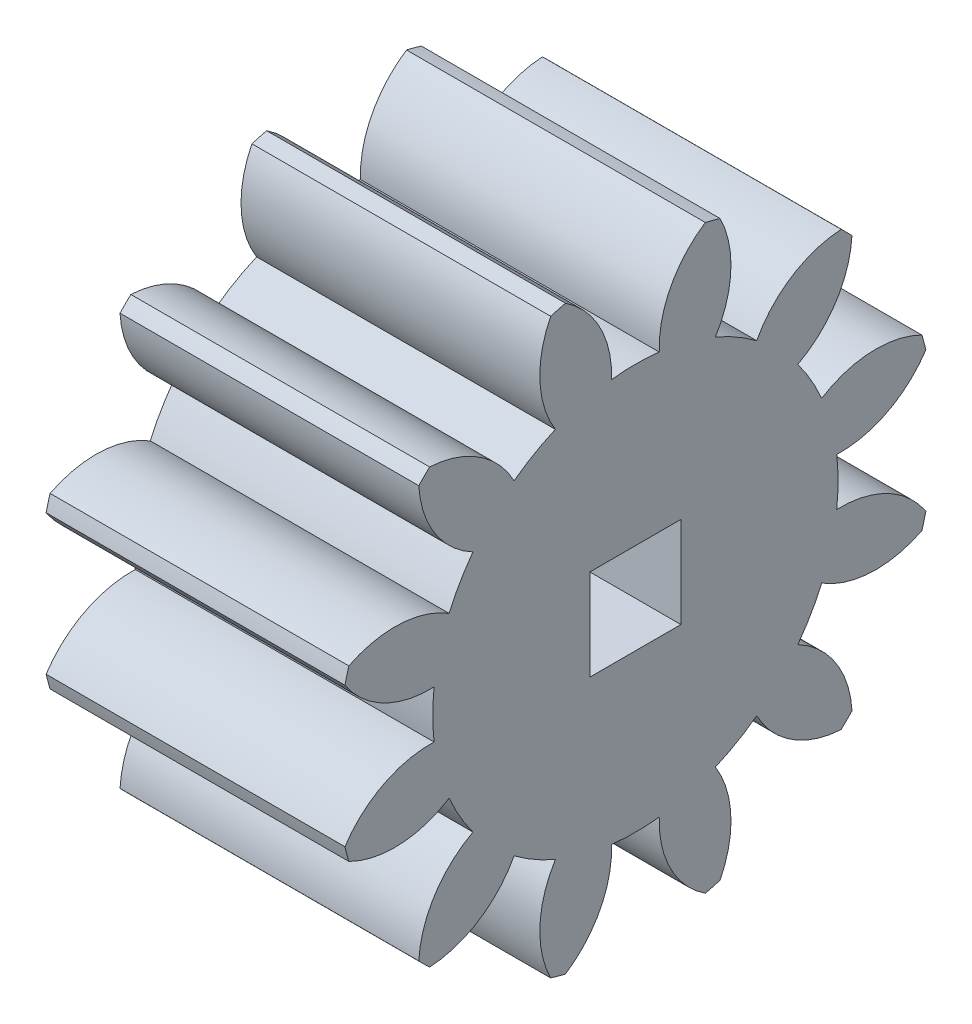
from build123d import *

# Parameters (mm, degrees)
BASPROSKE_W        = 10.5
BASPROSKE_H        = 10.5
TOOTHCUT_DEPTH     = 19.186533479
TEETHCUTS_COUNT    = 12
TEETHCUTS_ANGLE    = 330
BORSKE_R           = 0.5
BORE_DEPTH         = 50.0000508
SKETCH1_W          = 3.2
SKETCH1_H          = 3.2
CUT_EXTRUDE1_DEPTH = 30


with BuildPart() as part:
    # BasProSke → Base-Revolve (revolve)
    with BuildSketch(Plane(origin=(0, 0, 0), x_dir=(1, 0, 0), z_dir=(0, 1, 0)), mode=Mode.PRIVATE) as base_revolve_sk:
        with Locations((5.25, 5.25)):
            Rectangle(BASPROSKE_W, BASPROSKE_H)
    revolve(base_revolve_sk.sketch.rotate(Axis((-10, 0, 0), (1, 0, 0)), 180), axis=Axis((-10, 0, 0), (1, 0, 0)))

    # TooCutSke → ToothCut (cut, through all)
    with BuildSketch(Plane(origin=(0, 0, 0), x_dir=(0, 0, -1), z_dir=(1, 0, 0))):
        with BuildLine():
            ThreePointArc((0.837751456, 7.074570552), (0, 7.124), (-0.837751456, 7.074570552))
            ThreePointArc((-0.837751456, 7.074570552), (-1.245380016, 8.868946541), (-2.486473743, 10.227487154))
            ThreePointArc((-2.486473743, 10.227487154), (0, 10.5254), (2.486473743, 10.227487154))
            ThreePointArc((2.486473743, 10.227487154), (1.245380016, 8.868946541), (0.837751456, 7.074570552))
        make_face()
    toothcut = extrude(amount=TOOTHCUT_DEPTH, mode=Mode.SUBTRACT)

    # TeethCuts: ToothCut ×12 about axis
    teethcuts_axis = Axis((-10, 0, 0), (1, 0, 0))
    for i in range(1, TEETHCUTS_COUNT):
        add(toothcut.rotate(teethcuts_axis, i * TEETHCUTS_ANGLE / (TEETHCUTS_COUNT - 1)), mode=Mode.SUBTRACT)

    # BorSke → Bore (cut, symmetric)
    with BuildSketch(Plane(origin=(0, 0, 0), x_dir=(0, 0, -1), z_dir=(1, 0, 0))):
        with Locations(Location((0, 0, 0), (0, 0, 180))):
            Circle(BORSKE_R)
    extrude(amount=BORE_DEPTH, both=True, mode=Mode.SUBTRACT)

    # Sketch1 → Cut-Extrude1 (cut)
    with BuildSketch(Plane(origin=(10.5, 0, 0), x_dir=(0, 0, -1), z_dir=(1, 0, 0))):
        Rectangle(SKETCH1_W, SKETCH1_H)
    extrude(amount=-CUT_EXTRUDE1_DEPTH, mode=Mode.SUBTRACT)


solid = part.part
